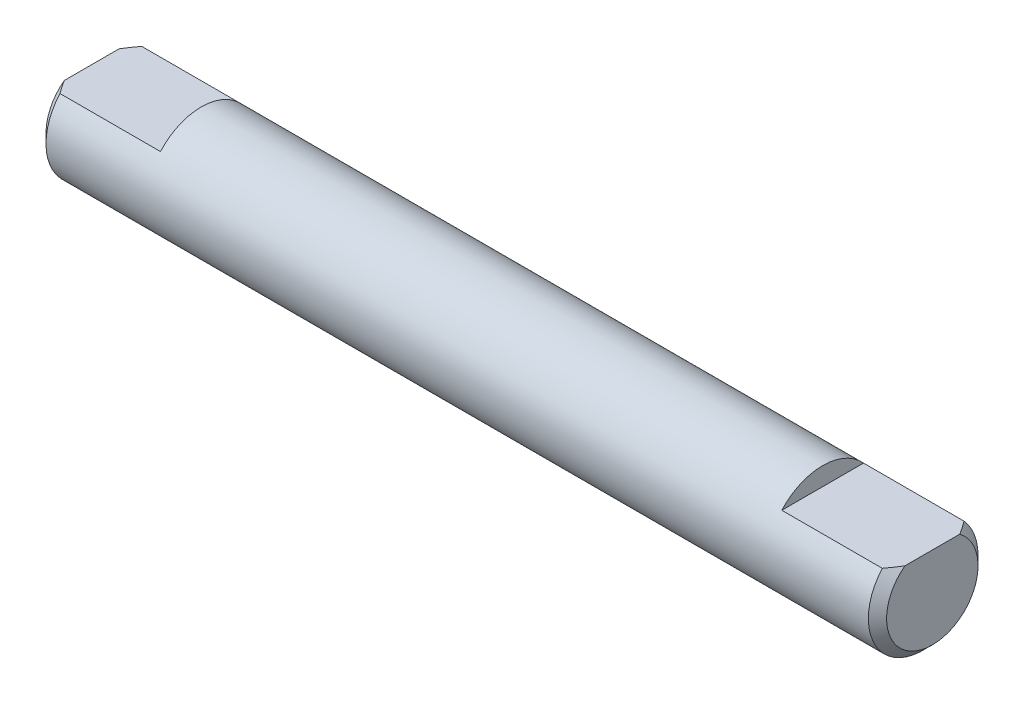
from build123d import *

# Parameters (mm, degrees)
SKETCH2_W          = 46
SKETCH2_H          = 3
CUT_EXTRUDE3_DEPTH = 6
CUT_EXTRUDE4_DEPTH = 6
CHAMFER2_SIZE      = 0.5


with BuildPart() as part:
    # Sketch2 → Revolve2 (revolve)
    with BuildSketch(Plane.XY):
        with Locations((23, -1.5)):
            Rectangle(SKETCH2_W, SKETCH2_H)
    revolve(axis=Axis((0, 0, 0), (1, 0, 0)))

    # Sketch7 → Cut-Extrude3 (cut)
    with BuildSketch(Plane(origin=(46, 0, 0), x_dir=(0, 0, -1), z_dir=(1, 0, 0))):
        with BuildLine():
            Line((-2.236067977, 2), (2.236067977, 2))
            ThreePointArc((2.236067977, 2), (0, 3), (-2.236067977, 2))
        make_face()
    extrude(amount=-CUT_EXTRUDE3_DEPTH, mode=Mode.SUBTRACT)

    # Sketch8 → Cut-Extrude4 (cut)
    with BuildSketch(Plane.ZY):
        with BuildLine():
            Line((-2.236067977, 2), (2.236067977, 2))
            ThreePointArc((2.236067977, 2), (0, 3), (-2.236067977, 2))
        make_face()
    extrude(amount=-CUT_EXTRUDE4_DEPTH, mode=Mode.SUBTRACT)

    # Chamfer2
    chamfer2_edges = [part.edges().sort_by_distance(p)[0] for p in [
        (46, -1.224744871, -2.738612788),
        (0, -1.224744871, -2.738612788),
    ]]
    chamfer(chamfer2_edges, length=CHAMFER2_SIZE)


solid = part.part
